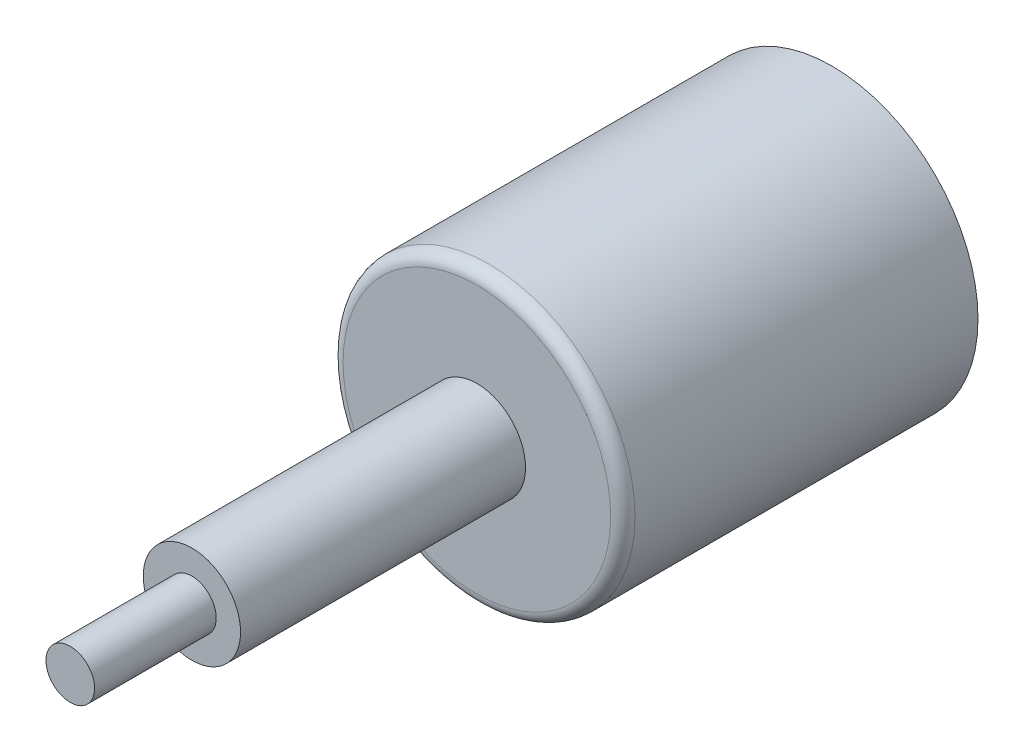
from build123d import *

# Parameters (mm, degrees)
ESQUISSE1_R      = 12
EXTRUSION1_DEPTH = 29.2
CONG_1_R         = 1
ESQUISSE2_R      = 4
EXTRUSION2_DEPTH = 23.43
ESQUISSE3_R      = 2
EXTRUSION3_DEPTH = 10


with BuildPart() as part:
    # Esquisse1 → Extrusion1 (new body)
    with BuildSketch(Plane.XY):
        Circle(ESQUISSE1_R)
    extrude(amount=EXTRUSION1_DEPTH)

    # Congé1
    cong_1_edges = [part.edges().sort_by_distance(p)[0] for p in [
        (-12, 0, 29.2),
    ]]
    fillet(cong_1_edges, radius=CONG_1_R)

    # Esquisse2 → Extrusion2 (add)
    with BuildSketch(Plane.XY.offset(29.2)):
        Circle(ESQUISSE2_R)
    extrude(amount=EXTRUSION2_DEPTH)

    # Esquisse3 → Extrusion3 (add)
    with BuildSketch(Plane.XY.offset(52.63)):
        Circle(ESQUISSE3_R)
    extrude(amount=EXTRUSION3_DEPTH)


solid = part.part
